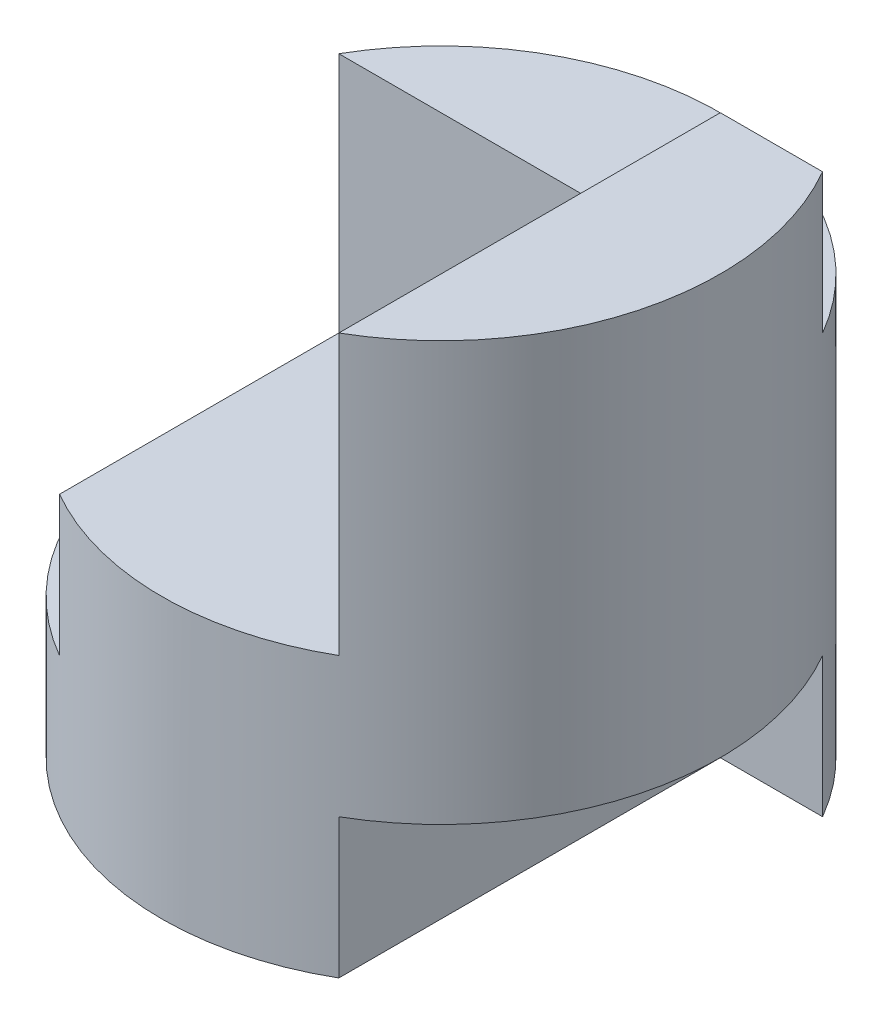
from build123d import *

# Parameters (mm, degrees)
SKETCH1_R               = 2
BOSS_EXTRUDE1_DEPTH     = 4
SKETCH2_W               = 1
SKETCH2_H               = 1
CUT_EXTRUDE1_DEPTH      = 3
CUT_EXTRUDE1_DEPTH_BACK = 1
CUT_EXTRUDE4_DEPTH      = 1


with BuildPart() as part:
    # Sketch1 → Boss-Extrude1 (new body)
    with BuildSketch(Plane(origin=(0, 0, 0), x_dir=(1, 0, 0), z_dir=(0, 1, 0))):
        Circle(SKETCH1_R)
    extrude(amount=BOSS_EXTRUDE1_DEPTH)

    # Sketch2 → Cut-Extrude1 (cut, two sides)
    with BuildSketch(Plane.XY) as cut_extrude1_sk:
        Polygon((1, 2), (1, 3), (1, 4), (-2, 4), (-2, 3), (-2, 1), (-1, 1), (-1, 2), align=None)
        with Locations((1.5, 0.5)):
            Rectangle(SKETCH2_W, SKETCH2_H)
    extrude(amount=CUT_EXTRUDE1_DEPTH, mode=Mode.SUBTRACT)
    extrude(cut_extrude1_sk.sketch, amount=-CUT_EXTRUDE1_DEPTH_BACK, mode=Mode.SUBTRACT)

    # Sketch5 → Cut-Extrude4 (cut)
    with BuildSketch(Plane(origin=(0, 4, 0), x_dir=(1, 0, 0), z_dir=(0, 1, 0))):
        with BuildLine():
            Line((-1.732050808, 1), (1.732050808, 1))
            ThreePointArc((1.732050808, 1), (0, 2), (-1.732050808, 1))
        make_face()
    extrude(amount=-CUT_EXTRUDE4_DEPTH, mode=Mode.SUBTRACT)


solid = part.part
